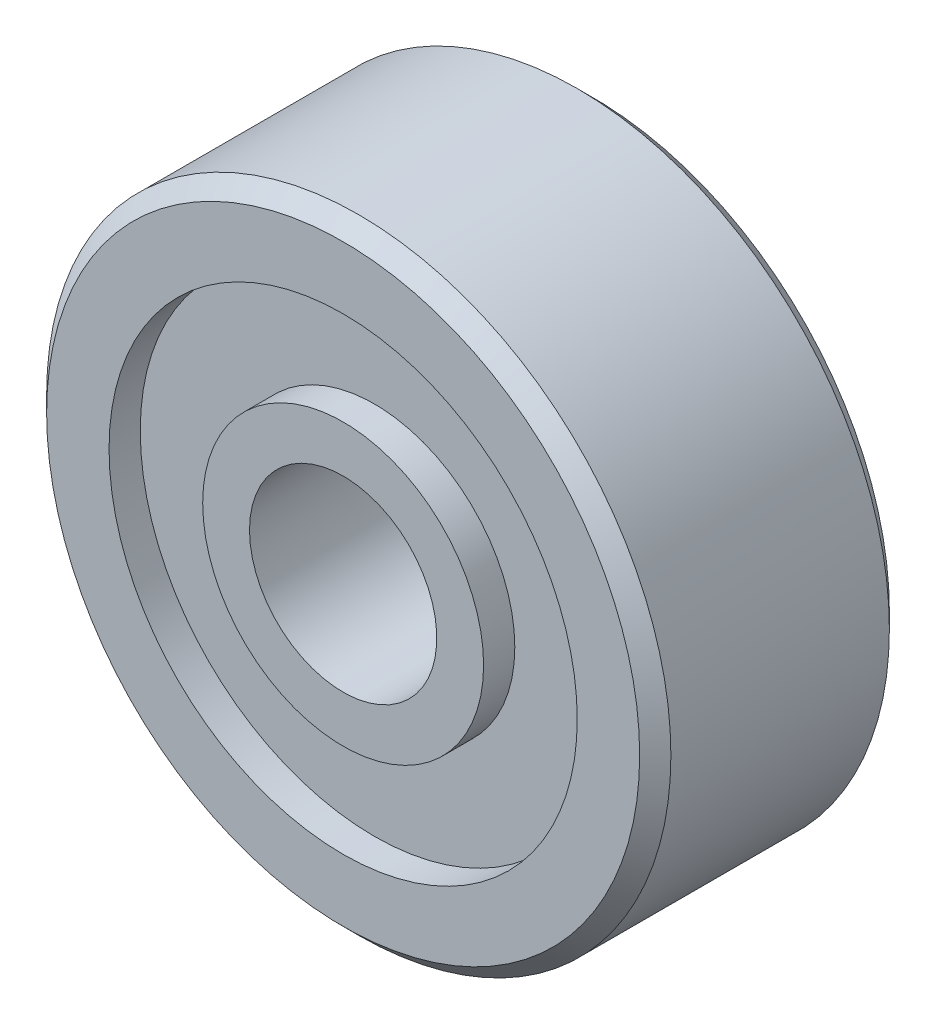
from build123d import *


with BuildPart() as part:
    # Sketch1 → Revolve1 (revolve)
    with BuildSketch(Plane.XZ):
        Polygon((6.5, 1.25), (6.25, 1.5), (5.25, 1.5), (5.25, 1), (3.75, 1), (3.75, 1.5), (3, 1.5), (3, -2.5), (3.75, -2.5), (3.75, -2), (5.25, -2), (5.25, -2.5), (6.25, -2.5), (6.5, -2.25), align=None)
    revolve(axis=Axis((1.5, 0, 2.5), (0, 0, -1)))


solid = part.part
